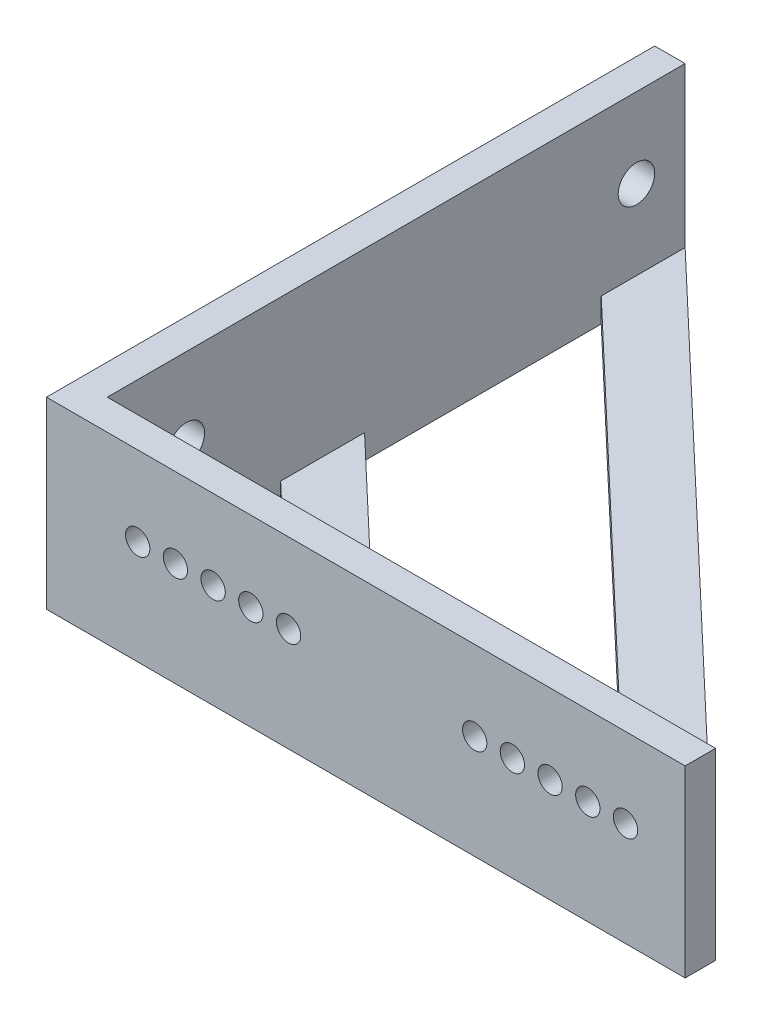
from build123d import *

# Parameters (mm, degrees)
SKETCH1_W           = 50
SKETCH1_H           = 15.1
BOSS_EXTRUDE1_DEPTH = 2.5
SKETCH3_R           = 1.5
CUT_EXTRUDE1_DEPTH  = 3.5
SKETCH4_W           = 2.5
SKETCH4_H           = 15.1
BOSS_EXTRUDE2_DEPTH = 50
SKETCH6_R           = 1
CUT_EXTRUDE2_DEPTH  = 45
SKETCH8_W           = 47.5
SKETCH8_H           = 2
BOSS_EXTRUDE3_DEPTH = 50
CUT_EXTRUDE3_DEPTH  = 3


with BuildPart() as part:
    # Sketch1 → Boss-Extrude1 (new body)
    with BuildSketch(Plane(origin=(0, 0, 0), x_dir=(0, 0, -1), z_dir=(1, 0, 0))):
        with Locations((25, 7.55)):
            Rectangle(SKETCH1_W, SKETCH1_H)
    extrude(amount=BOSS_EXTRUDE1_DEPTH)

    # Sketch3 → Cut-Extrude1 (cut, through all)
    with BuildSketch(Plane(origin=(2.5, 0, 0), x_dir=(0, 0, -1), z_dir=(1, 0, 0))):
        with Locations((46, 8.55)):
            Circle(SKETCH3_R)
        with Locations((9, 8.55)):
            Circle(SKETCH3_R)
    extrude(amount=-CUT_EXTRUDE1_DEPTH, mode=Mode.SUBTRACT)

    # Sketch4 → Boss-Extrude2 (add)
    with BuildSketch(Plane(origin=(2.5, 0, 0), x_dir=(0, 0, -1), z_dir=(1, 0, 0))):
        with Locations((1.25, 7.55)):
            Rectangle(SKETCH4_W, SKETCH4_H)
    extrude(amount=BOSS_EXTRUDE2_DEPTH)

    # Sketch6 → Cut-Extrude2 (cut)
    with BuildSketch(Plane(origin=(0, 0, -2.5), x_dir=(-1, 0, 0), z_dir=(0, 0, -1))):
        with Locations((-7.5, 8.55)):
            Circle(SKETCH6_R)
        with Locations((-10.6, 8.55)):
            Circle(SKETCH6_R)
        with Locations((-13.7, 8.55)):
            Circle(SKETCH6_R)
        with Locations((-16.8, 8.55)):
            Circle(SKETCH6_R)
        with Locations((-19.9, 8.55)):
            Circle(SKETCH6_R)
        with Locations((-35.2, 8.55)):
            Circle(SKETCH6_R)
        with Locations((-38.3, 8.55)):
            Circle(SKETCH6_R)
        with Locations((-41.4, 8.55)):
            Circle(SKETCH6_R)
        with Locations((-44.5, 8.55)):
            Circle(SKETCH6_R)
        with Locations((-47.6, 8.55)):
            Circle(SKETCH6_R)
    extrude(amount=-CUT_EXTRUDE2_DEPTH, mode=Mode.SUBTRACT)

    # Sketch8 → Boss-Extrude3 (add)
    with BuildSketch(Plane(origin=(2.5, 0, 0), x_dir=(0, 0, -1), z_dir=(1, 0, 0))):
        with Locations((26.25, 1)):
            Rectangle(SKETCH8_W, SKETCH8_H)
    extrude(amount=BOSS_EXTRUDE3_DEPTH)

    # Sketch9 → Cut-Extrude3 (cut, through all)
    with BuildSketch(Plane(origin=(0, 2, 0), x_dir=(1, 0, 0), z_dir=(0, 1, 0))):
        Polygon((45.240466198, 2.5), (2.5, 43.103442888), (2.5, 23.646557112), (24.759533802, 2.5), align=None)
        Polygon((52.5, 2.5), (2.5, 50), (52.5, 50), align=None)
        Polygon((17.5, 2.5), (2.5, 16.75), (2.5, 2.5), align=None)
    extrude(amount=-CUT_EXTRUDE3_DEPTH, mode=Mode.SUBTRACT)


solid = part.part
